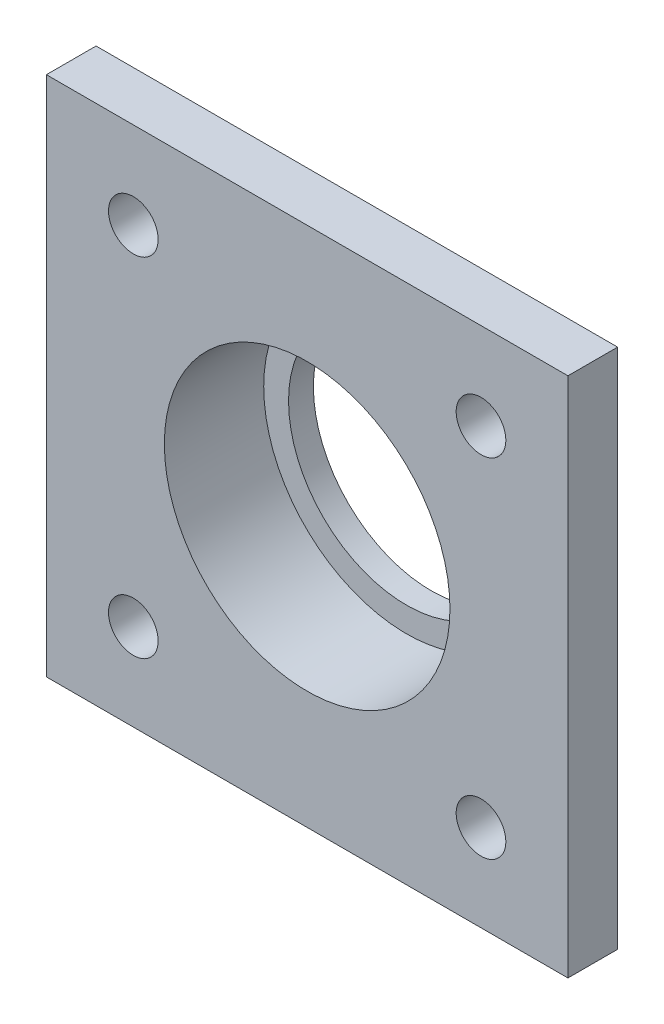
from build123d import *

# Parameters (mm, degrees)
SKETCH1_W           = 42
SKETCH1_H           = 42
SKETCH1_R           = 2
SKETCH1_R_2         = 11.5
BOSS_EXTRUDE1_DEPTH = 4
SKETCH2_R           = 15
SKETCH2_R_2         = 11.5
BOSS_EXTRUDE2_DEPTH = 6
SKETCH3_R           = 11.5
SKETCH3_R_2         = 9.5
BOSS_EXTRUDE3_DEPTH = 2
FILLET1_R           = 2


with BuildPart() as part:
    # Sketch1 → Boss-Extrude1 (new body)
    with BuildSketch(Plane.XY):
        Rectangle(SKETCH1_W, SKETCH1_H)
        with Locations((-14, -14)):
            Circle(SKETCH1_R, mode=Mode.SUBTRACT)
        with Locations((14, 14)):
            Circle(SKETCH1_R, mode=Mode.SUBTRACT)
        with Locations((14, -14)):
            Circle(SKETCH1_R, mode=Mode.SUBTRACT)
        with Locations((-14, 14)):
            Circle(SKETCH1_R, mode=Mode.SUBTRACT)
        Circle(SKETCH1_R_2, mode=Mode.SUBTRACT)
    extrude(amount=BOSS_EXTRUDE1_DEPTH)

    # Sketch2 → Boss-Extrude2 (add)
    with BuildSketch(Plane.XY):
        Circle(SKETCH2_R)
        Circle(SKETCH2_R_2, mode=Mode.SUBTRACT)
    extrude(amount=-BOSS_EXTRUDE2_DEPTH)

    # Sketch3 → Boss-Extrude3 (add)
    with BuildSketch(Plane(origin=(0, 0, -6), x_dir=(-1, 0, 0), z_dir=(0, 0, -1))):
        Circle(SKETCH3_R)
        Circle(SKETCH3_R_2, mode=Mode.SUBTRACT)
    extrude(amount=-BOSS_EXTRUDE3_DEPTH)

    # Fillet1
    fillet1_edges = [part.edges().sort_by_distance(p)[0] for p in [
        (-15, 0, 0),
    ]]
    fillet(fillet1_edges, radius=FILLET1_R)


solid = part.part
